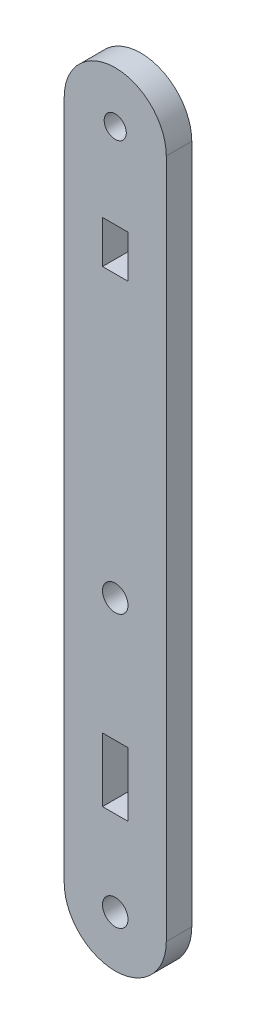
from build123d import *

# Parameters (mm, degrees)
MODEL_R             = 1.5
MODEL_R_2           = 1.299999998
MODEL_W             = 3
MODEL_H             = 5
MODEL_H_2           = 7.5
BOSS_EXTRUDE1_DEPTH = 3


with BuildPart() as part:
    # Model → Boss-Extrude1 (new body)
    with BuildSketch(Plane.XY):
        with BuildLine():
            Line((36.3632, 82.806053789), (36.3632, 2.806053789))
            ThreePointArc((36.3632, 2.806053789), (42.36315, -3.193996211), (48.3632, 2.805953789))
            Line((48.3632, 2.805953789), (48.3632, 82.806053789))
            ThreePointArc((48.3632, 82.806053789), (42.3632, 88.806053789), (36.3632, 82.806053789))
        make_face()
        with Locations((42.3632, 34.805953789)):
            Circle(MODEL_R, mode=Mode.SUBTRACT)
        with Locations((42.366358052, 2.813035516)):
            Circle(MODEL_R, mode=Mode.SUBTRACT)
        with Locations((42.3632, 82.806053789)):
            Circle(MODEL_R_2, mode=Mode.SUBTRACT)
        with Locations((42.3632, 70.306053789)):
            Rectangle(MODEL_W, MODEL_H, mode=Mode.SUBTRACT)
        with Locations((42.3632, 16.556053789)):
            Rectangle(MODEL_W, MODEL_H_2, mode=Mode.SUBTRACT)
    extrude(amount=BOSS_EXTRUDE1_DEPTH)


solid = part.part
